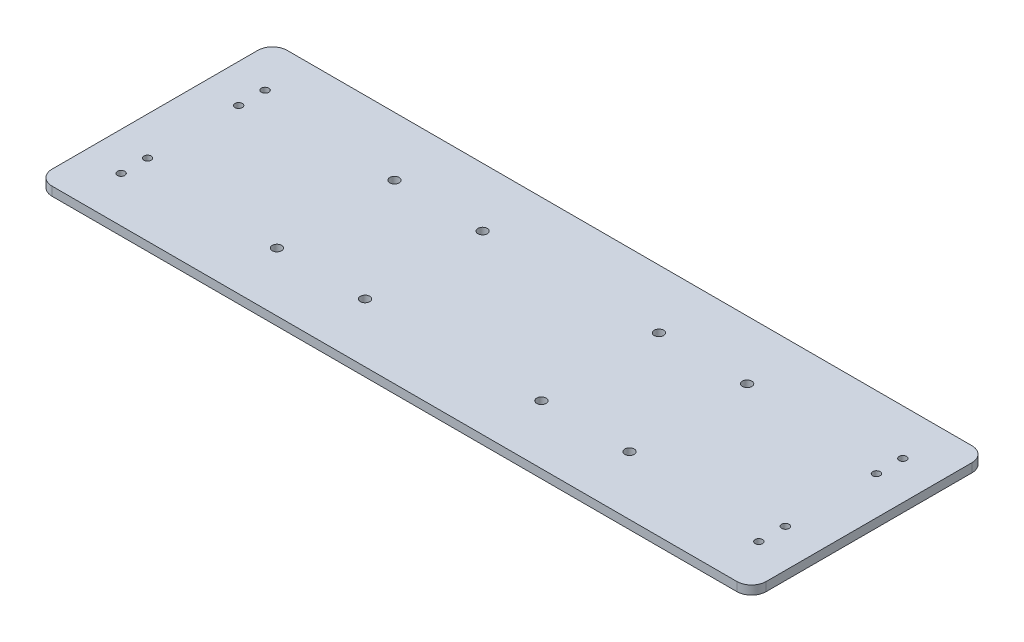
from build123d import *

# Parameters (mm, degrees)
SKETCH_1_W          = 243
SKETCH_1_H          = 80
EXTRUDE_1_DEPTH     = 3
SKETCH_2_R          = 1.25
CUT_EXTRUDE_1_DEPTH = 10
FILLET_1_R          = 5
SKETCH_3_R          = 1.6
CUT_EXTRUDE_2_DEPTH = 10


with BuildPart() as part:
    # 草图1 → 凸台-拉伸1 (new body)
    with BuildSketch(Plane(origin=(0, 0, 0), x_dir=(1, 0, 0), z_dir=(0, 1, 0))):
        with Locations((121.5, 40)):
            Rectangle(SKETCH_1_W, SKETCH_1_H)
    extrude(amount=EXTRUDE_1_DEPTH)

    # 草图2 → 切除-拉伸1 (cut)
    with BuildSketch(Plane.XZ):
        with Locations((13, -64.5)):
            Circle(SKETCH_2_R)
        with Locations((13, -55.5)):
            Circle(SKETCH_2_R)
        with Locations((13, -24.5)):
            Circle(SKETCH_2_R)
        with Locations((13, -15.5)):
            Circle(SKETCH_2_R)
        with Locations((230, -55.5)):
            Circle(SKETCH_2_R)
        with Locations((230, -64.5)):
            Circle(SKETCH_2_R)
        with Locations((230, -24.5)):
            Circle(SKETCH_2_R)
        with Locations((230, -15.5)):
            Circle(SKETCH_2_R)
    extrude(amount=-CUT_EXTRUDE_1_DEPTH, mode=Mode.SUBTRACT)

    # 圆角1
    fillet_1_edges = [part.edges().sort_by_distance(p)[0] for p in [
        (0, 1.5, -80),
        (243, 1.5, -80),
        (243, 1.5, 0),
        (0, 1.5, 0),
    ]]
    fillet(fillet_1_edges, radius=FILLET_1_R)

    # 草图3 → 切除-拉伸2 (cut)
    with BuildSketch(Plane.XZ):
        with Locations((61.5, -20)):
            Circle(SKETCH_3_R)
        with Locations((91.5, -20)):
            Circle(SKETCH_3_R)
        with Locations((151.5, -20)):
            Circle(SKETCH_3_R)
        with Locations((181.5, -20)):
            Circle(SKETCH_3_R)
        with Locations((181.5, -60)):
            Circle(SKETCH_3_R)
        with Locations((151.5, -60)):
            Circle(SKETCH_3_R)
        with Locations((91.5, -60)):
            Circle(SKETCH_3_R)
        with Locations((61.5, -60)):
            Circle(SKETCH_3_R)
    extrude(amount=-CUT_EXTRUDE_2_DEPTH, mode=Mode.SUBTRACT)


solid = part.part
